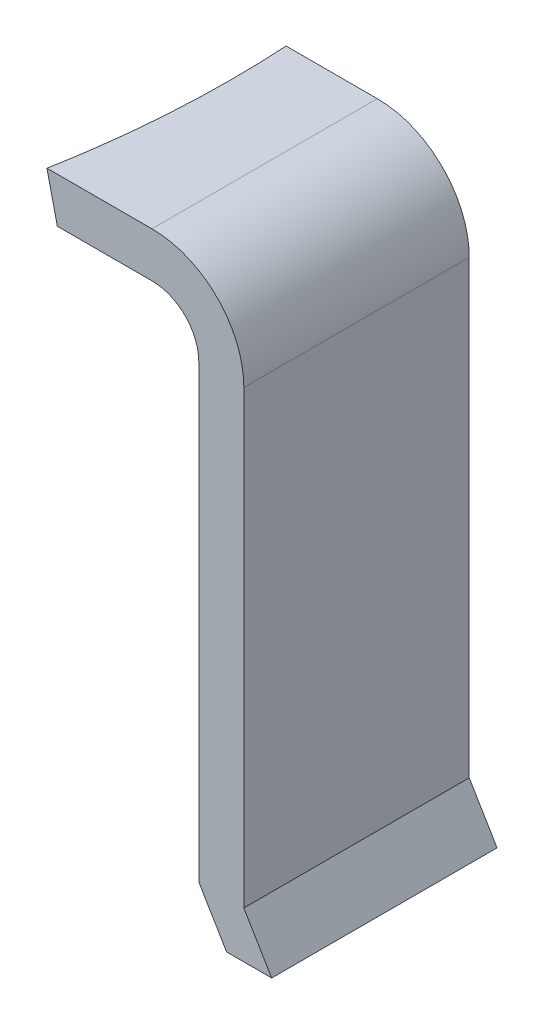
from build123d import *

# Parameters (mm, degrees)
BOSS_EXTRUDE1_DEPTH     = 10
SKETCH2_W               = 10
SKETCH2_H               = 2.000056303
BOSS_EXTRUDE2_DEPTH     = 5
CUT_EXTRUDE3_DEPTH      = 11
BOSS_EXTRUDE7_DEPTH     = 10
SKETCH10_R              = 42.5
CUT_EXTRUDE5_DEPTH      = 2
CUT_EXTRUDE5_DEPTH_BACK = 2


with BuildPart() as part:
    # Sketch1 → Boss-Extrude1 (new body)
    with BuildSketch(Plane.XY):
        with BuildLine():
            Line((-0.275264024, 0.618336289), (-0.275264024, 20.618336289))
            ThreePointArc((-0.275264024, 20.618336289), (-1.471073772, 23.494405264), (-4.353490365, 24.674832426))
            Line((-4.353490365, 24.674832426), (-4.353490365, 22.674776123))
            ThreePointArc((-4.353490365, 22.674776123), (-2.885297366, 22.080181828), (-2.275264024, 20.618336289))
            Line((-2.275264024, 20.618336289), (-2.275264024, 0.618336289))
            Line((-2.275264024, 0.618336289), (-1.040586258, -1.454212886))
            Line((-1.040586258, -1.454212886), (0.959413742, -1.454212886))
            Line((0.959413742, -1.454212886), (-0.275264024, 0.618336289))
        make_face()
    extrude(amount=BOSS_EXTRUDE1_DEPTH)

    # Sketch2 → Boss-Extrude2 (add)
    with BuildSketch(Plane.ZY.offset(4.353490365)):
        with Locations((5, 23.674804275)):
            Rectangle(SKETCH2_W, SKETCH2_H)
    extrude(amount=BOSS_EXTRUDE2_DEPTH)

    # Sketch7 → Cut-Extrude3 (cut, through all)
    with BuildSketch(Plane.XY.offset(10)):
        with BuildLine():
            Line((-9.353490365, 24.674832426), (-8.891740984, 22.674776123))
            ThreePointArc((-8.891740984, 22.674776123), (-9.122615674, 22.648471274), (-9.353490365, 22.674776123))
            Line((-9.353490365, 22.674776123), (-9.353490365, 24.674832426))
        make_face()
    extrude(amount=-CUT_EXTRUDE3_DEPTH, mode=Mode.SUBTRACT)

    # Sketch8 → Boss-Extrude7 (add, through all)
    with BuildSketch(Plane.XY.offset(10)):
        Polygon((-9.122615674, 23.674804274), (-50.533343428, 14.114384465), (-50.555838533, 14.211821471), (-9.14511078, 23.772241281), align=None)
    extrude(amount=-BOSS_EXTRUDE7_DEPTH)

    # Sketch10 → Cut-Extrude5 (cut, two sides)
    with BuildSketch(Plane(origin=(-5.673302165, 24.573771456, 0), x_dir=(0.974370065, 0.224951054, 0), z_dir=(-0.224951054, 0.974370065, 0))) as cut_extrude5_sk:
        with Locations((-45.063131443, -2.5)):
            Circle(SKETCH10_R)
    extrude(amount=CUT_EXTRUDE5_DEPTH, mode=Mode.SUBTRACT)
    extrude(cut_extrude5_sk.sketch, amount=-CUT_EXTRUDE5_DEPTH_BACK, mode=Mode.SUBTRACT)


solid = part.part
